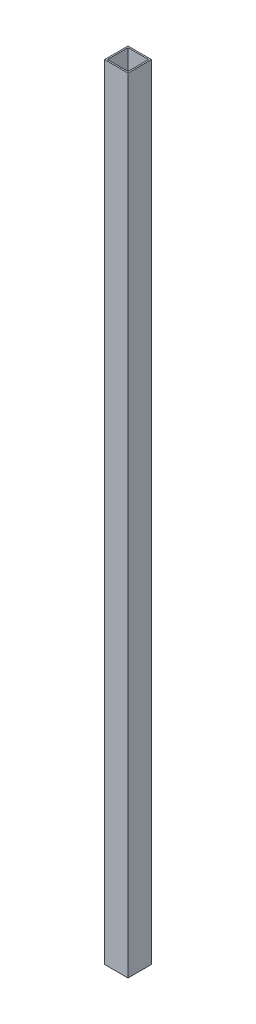
from build123d import *

# Parameters (mm, degrees)
SKETCH1_W           = 25.4
SKETCH1_H           = 25.4
SKETCH1_W_2         = 22.352
SKETCH1_H_2         = 22.352
BOSS_EXTRUDE1_DEPTH = 848.868


with BuildPart() as part:
    # Sketch1 → Boss-Extrude1 (new body)
    with BuildSketch(Plane(origin=(0, 0, 0), x_dir=(1, 0, 0), z_dir=(0, 1, 0))):
        with Locations((-1.85505618, 4.566292135)):
            Rectangle(SKETCH1_W, SKETCH1_H)
        with Locations((-1.85505618, 4.566292135)):
            Rectangle(SKETCH1_W_2, SKETCH1_H_2, mode=Mode.SUBTRACT)
    extrude(amount=BOSS_EXTRUDE1_DEPTH)


solid = part.part
